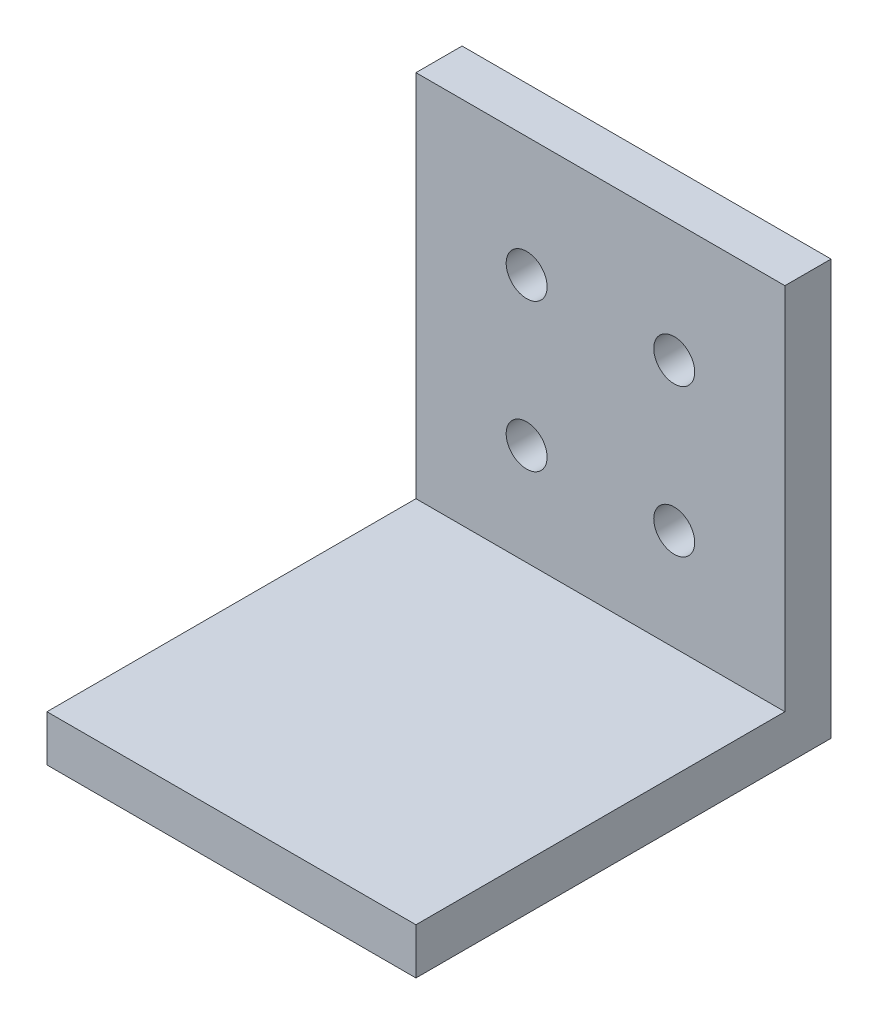
from build123d import *

# Parameters (mm, degrees)
SKETCH1_W            = 25.4
SKETCH1_H            = 28.575
BOSS_EXTRUDE1_DEPTH  = 3.175
SKETCH2_W            = 25.4
SKETCH2_H            = 3.175
BOSS_EXTRUDE2_DEPTH  = 25.4
SKETCH4_R            = 1.4097
CUT_EXTRUDE1_DEPTH   = 29.575
LPATTERN1_COUNT      = 2
LPATTERN1_PITCH      = 10.16
LPATTERN1_COUNT_DIR2 = 2
LPATTERN1_PITCH_DIR2 = 10.16


with BuildPart() as part:
    # Sketch1 → Boss-Extrude1 (new body)
    with BuildSketch(Plane.XY):
        Rectangle(SKETCH1_W, SKETCH1_H)
    extrude(amount=BOSS_EXTRUDE1_DEPTH)

    # Sketch2 → Boss-Extrude2 (add)
    with BuildSketch(Plane.XY.offset(3.175)):
        with Locations((0, -12.7)):
            Rectangle(SKETCH2_W, SKETCH2_H)
    extrude(amount=BOSS_EXTRUDE2_DEPTH)

    # Sketch4 → Cut-Extrude1 (cut, through all)
    with BuildSketch(Plane(origin=(0, 0, 0), x_dir=(-1, 0, 0), z_dir=(0, 0, -1))):
        with Locations((-5.08, 6.0325)):
            Circle(SKETCH4_R)
    cut_extrude1 = extrude(amount=-CUT_EXTRUDE1_DEPTH, mode=Mode.SUBTRACT)

    # LPattern1: Cut-Extrude1 2 × 2
    with Locations(*[(-j * LPATTERN1_PITCH_DIR2, -i * LPATTERN1_PITCH, 0) for i in range(LPATTERN1_COUNT) for j in range(LPATTERN1_COUNT_DIR2) if (i, j) != (0, 0)]):
        add(cut_extrude1, mode=Mode.SUBTRACT)


solid = part.part
